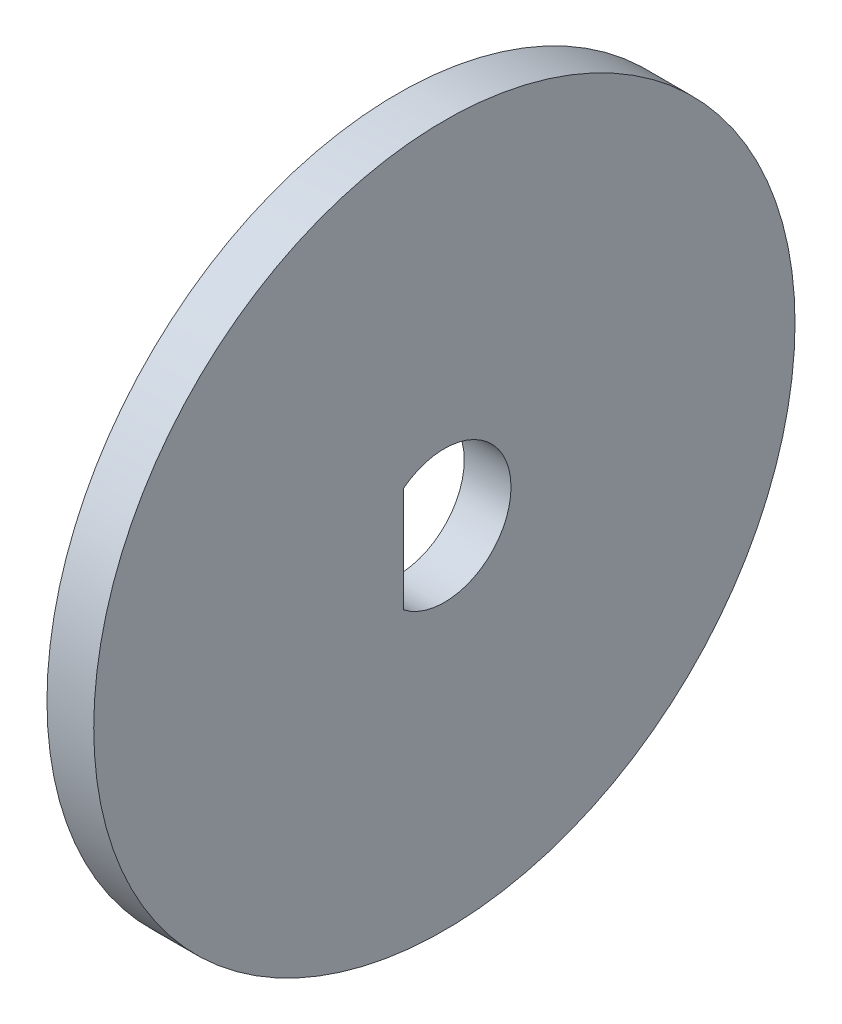
from build123d import *

# Parameters (mm, degrees)
SKETCH1_R           = 15
BOSS_EXTRUDE1_DEPTH = 2
CUT_EXTRUDE1_DEPTH  = 3


with BuildPart() as part:
    # Sketch1 → Boss-Extrude1 (new body)
    with BuildSketch(Plane(origin=(0, 0, 0), x_dir=(0, 0, -1), z_dir=(1, 0, 0))):
        Circle(SKETCH1_R)
    extrude(amount=BOSS_EXTRUDE1_DEPTH)

    # Sketch2 → Cut-Extrude1 (cut, through all)
    with BuildSketch(Plane(origin=(2, 0, 0), x_dir=(0, 0, -1), z_dir=(1, 0, 0))):
        with BuildLine():
            Line((-1.749285568, 2.25), (-1.749285568, -2.25))
            ThreePointArc((-1.749285568, -2.25), (2.85, 0), (-1.749285568, 2.25))
        make_face()
    extrude(amount=-CUT_EXTRUDE1_DEPTH, mode=Mode.SUBTRACT)


solid = part.part
